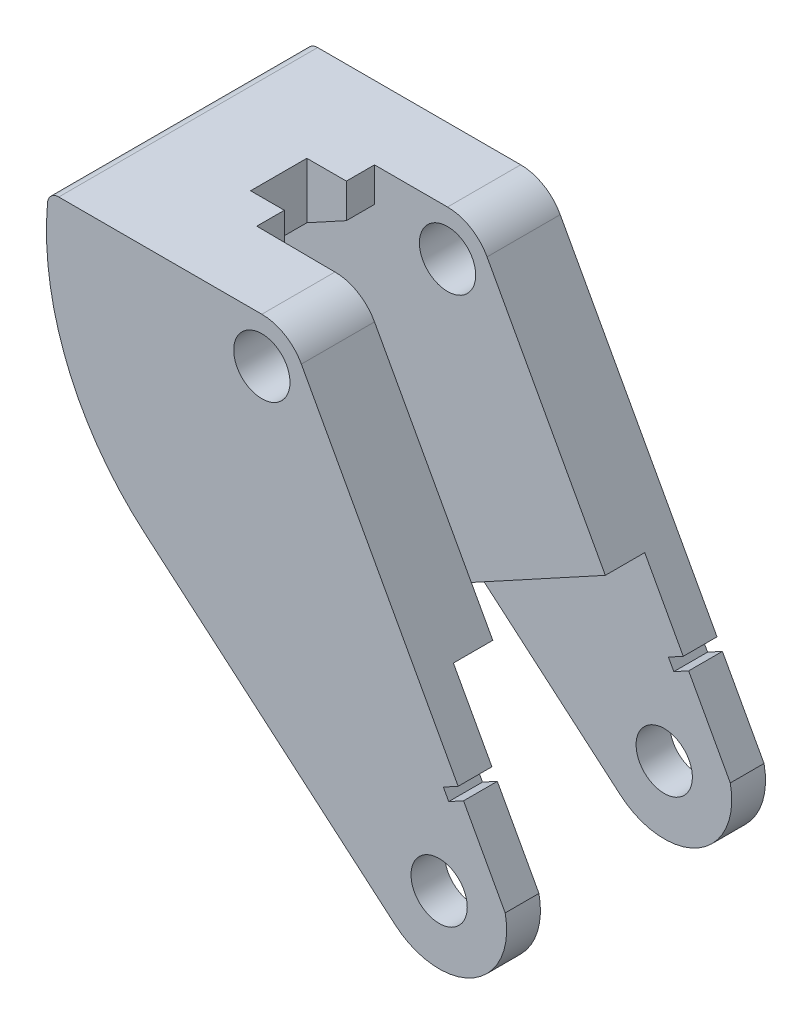
from build123d import *

# Parameters (mm, degrees)
SKETCH3_R           = 5
BOSS_EXTRUDE1_DEPTH = 46
CUT_EXTRUDE1_DEPTH  = 300
CUT_EXTRUDE2_DEPTH  = 300
FILLET1_R           = 2


with BuildPart() as part:
    # Sketch3 → Boss-Extrude1 (new body)
    with BuildSketch(Plane.XY):
        with BuildLine():
            Line((40.883413809, 0), (3, 0))
            ThreePointArc((3, 0), (2.797908937, -1.891823319), (2.668267594, -3.789988061))
            ThreePointArc((2.668267594, -3.789988061), (6.682027739, -25.953006917), (20.054026368, -44.077557338))
            Line((20.054026368, -44.077557338), (64.595472348, -82.12438231))
            ThreePointArc((64.595472348, -82.12438231), (78.521745085, -83.314776326), (84.128579654, -70.511592488))
            Line((84.128579654, -70.511592488), (76.728855671, -56.958627104))
            Line((76.728855671, -56.958627104), (74.095757005, -58.396261068))
            Line((74.095757005, -58.396261068), (73.137334363, -56.640861957))
            Line((73.137334363, -56.640861957), (75.770433029, -55.203227993))
            Line((75.770433029, -55.203227993), (47.905010252, -4.166309429))
            ThreePointArc((47.905010252, -4.166309429), (44.9657217, -1.119973671), (40.883413809, 0))
        make_face()
        with Locations((72.389421761, -73)):
            Circle(SKETCH3_R, mode=Mode.SUBTRACT)
        with BuildLine():
            ThreePointArc((45.883413809, -8), (40.609242405, -12.992477345), (35.913481792, -7.452482191))
            ThreePointArc((35.913481792, -7.452482191), (41.157585213, -3.007522655), (45.883413809, -8))
        make_face(mode=Mode.SUBTRACT)
    extrude(amount=BOSS_EXTRUDE1_DEPTH)

    # Sketch4 → Cut-Extrude1 (cut)
    with BuildSketch(Plane(origin=(35.151571892, 19.192252189, 0), x_dir=(0, 0, -1), z_dir=(0.877699555, 0.479211321, 0))):
        Polygon((-40, -114.23699177), (-40, -70.47572427), (-33, -70.47572427), (-33, -18.71699177), (-13, -18.71699177), (-13, -70.47572427), (-6, -70.47572427), (-6, -114.23699177), align=None)
    extrude(amount=-CUT_EXTRUDE1_DEPTH, mode=Mode.SUBTRACT)

    # Sketch5 → Cut-Extrude2 (cut)
    with BuildSketch(Plane(origin=(0, 0, 0), x_dir=(1, 0, 0), z_dir=(0, 1, 0))):
        Polygon((39.057908144, -13), (27.904150662, -13), (27.904150662, -18), (20.883413809, -18), (20.883413809, -28), (26.883413809, -28), (26.883413809, -32.893409872), (39.057908144, -33), align=None)
    extrude(amount=-CUT_EXTRUDE2_DEPTH, mode=Mode.SUBTRACT)

    # Fillet1
    fillet1_edges = [part.edges().sort_by_distance(p)[0] for p in [
        (3, 0, 23),
    ]]
    fillet(fillet1_edges, radius=FILLET1_R)


solid = part.part
